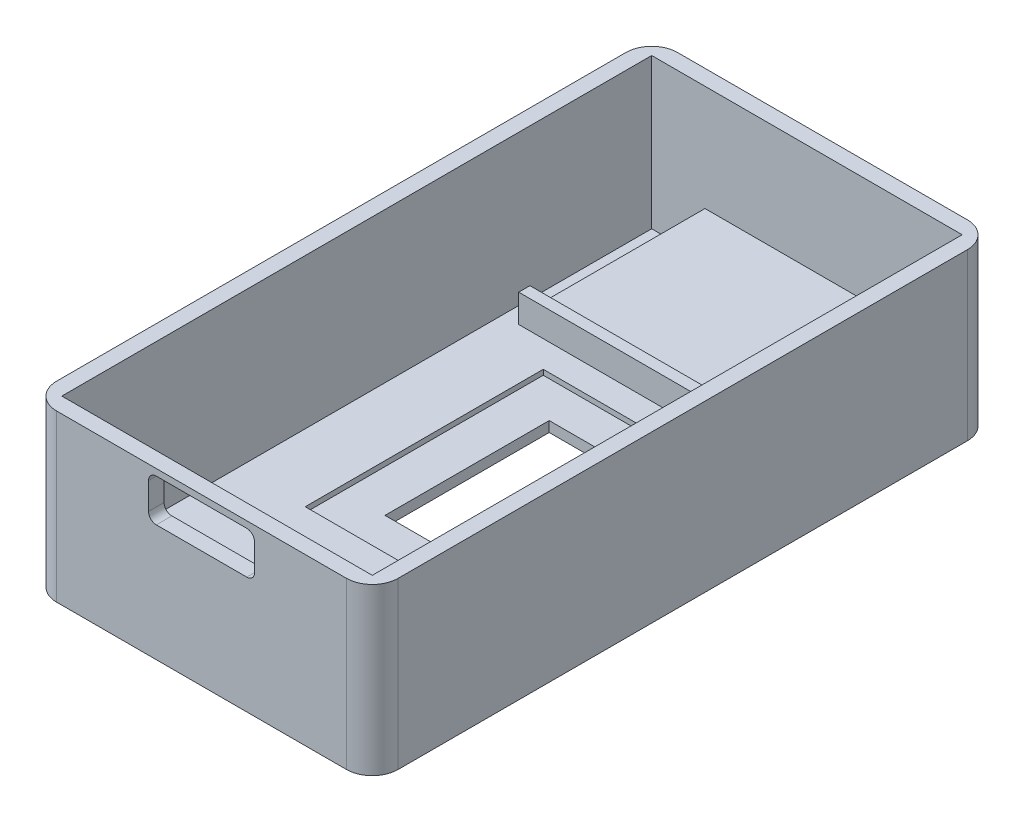
from build123d import *

# Parameters (mm, degrees)
SKETCH1_W               = 33
SKETCH1_H               = 60
BOSS_EXTRUDE1_DEPTH     = 16
SHELL1_T                = -1.5
CUT_EXTRUDE2_DEPTH      = 10
SKETCH5_R               = 1.25
CUT_EXTRUDE3_DEPTH      = 1
CUT_EXTRUDE3_DEPTH_BACK = 3
SKETCH6_W               = 19.561169912
SKETCH6_H               = 0.704256658
BOSS_EXTRUDE2_DEPTH     = 18
SKETCH7_W               = 19.561169912
SKETCH7_H               = 1.086114883
BOSS_EXTRUDE3_DEPTH     = 2
SKETCH9_W               = 16.960059774
SKETCH9_H               = 23
CUT_EXTRUDE4_DEPTH      = 0.5
CUT_EXTRUDE6_REACH      = 18
SKETCH11_W              = 8.91696513
SKETCH11_H              = 15.868910044
FILLET1_R               = 2.5


with BuildPart() as part:
    # Sketch1 → Boss-Extrude1 (new body)
    with BuildSketch(Plane(origin=(0, 0, 0), x_dir=(1, 0, 0), z_dir=(0, 1, 0))):
        with Locations((16.989591658, -18.738797177)):
            Rectangle(SKETCH1_W, SKETCH1_H)
    extrude(amount=BOSS_EXTRUDE1_DEPTH)

    # Shell1
    shell1_openings = [part.faces().sort_by_distance(p)[0] for p in [
        (16.989591658, 16, 18.738797177),
    ]]
    offset(amount=SHELL1_T, openings=shell1_openings, kind=Kind.INTERSECTION)

    # Sketch4 → Cut-Extrude2 (cut)
    with BuildSketch(Plane.XY.offset(48.738797177)):
        with BuildLine():
            Line((12.619091925, 11.287469293), (21.360091391, 11.287469293))
            ThreePointArc((21.360091391, 11.287469293), (21.890421477, 11.507139207), (22.110091391, 12.037469293))
            Line((22.110091391, 12.037469293), (22.110091391, 14.61730298))
            ThreePointArc((22.110091391, 14.61730298), (21.890421477, 15.147633066), (21.360091391, 15.36730298))
            Line((21.360091391, 15.36730298), (12.619091925, 15.36730298))
            ThreePointArc((12.619091925, 15.36730298), (12.088761839, 15.147633066), (11.869091925, 14.61730298))
            Line((11.869091925, 14.61730298), (11.869091925, 12.037469293))
            ThreePointArc((11.869091925, 12.037469293), (12.088761839, 11.507139207), (12.619091925, 11.287469293))
        make_face()
    extrude(amount=-CUT_EXTRUDE2_DEPTH, mode=Mode.SUBTRACT)

    # Sketch5 → Cut-Extrude3 (cut, two sides)
    with BuildSketch(Plane.XZ) as cut_extrude3_sk:
        with Locations((28.889591658, 45.188797177)):
            Circle(SKETCH5_R)
        with Locations((5.089591658, 45.188797177)):
            Circle(SKETCH5_R)
        with Locations((28.889591658, -5.611202823)):
            Circle(SKETCH5_R)
        with Locations((5.089591658, -5.611202823)):
            Circle(SKETCH5_R)
    extrude(amount=CUT_EXTRUDE3_DEPTH, mode=Mode.SUBTRACT)
    extrude(cut_extrude3_sk.sketch, amount=-CUT_EXTRUDE3_DEPTH_BACK, mode=Mode.SUBTRACT)

    # Sketch6 → Boss-Extrude2 (add)
    with BuildSketch(Plane.XY.offset(-9.761202823)):
        with Locations((16.918287272, 5.415344609)):
            Rectangle(SKETCH6_W, SKETCH6_H)
    extrude(amount=BOSS_EXTRUDE2_DEPTH)

    # Sketch7 → Boss-Extrude3 (add)
    with BuildSketch(Plane(origin=(0, 5.767472938, 0), x_dir=(1, 0, 0), z_dir=(0, 1, 0))):
        with Locations((16.918287272, -7.695739736)):
            Rectangle(SKETCH7_W, SKETCH7_H)
    extrude(amount=BOSS_EXTRUDE3_DEPTH)

    # Sketch9 → Cut-Extrude4 (cut)
    with BuildSketch(Plane(origin=(0, 1.5, 0), x_dir=(1, 0, 0), z_dir=(0, 1, 0))):
        with Locations((16.989591658, -18.738797177)):
            Rectangle(SKETCH9_W, SKETCH9_H)
    extrude(amount=-CUT_EXTRUDE4_DEPTH, mode=Mode.SUBTRACT)

    # Sketch11 → Cut-Extrude6 (cut, up to next)
    with BuildSketch(Plane.XZ, mode=Mode.PRIVATE) as cut_extrude6_sk1:
        with Locations((17.046338664, 18.676425411)):
            Rectangle(SKETCH11_W, SKETCH11_H)
    cut_extrude6_tool1 = extrude(cut_extrude6_sk1.sketch, amount=-CUT_EXTRUDE6_REACH, mode=Mode.PRIVATE) & part.part
    add(cut_extrude6_tool1.solids().sort_by_distance((17.046339, 0, 18.676425))[0], mode=Mode.SUBTRACT)

    # Fillet1
    fillet1_edges = [part.edges().sort_by_distance(p)[0] for p in [
        (0.489591658, 8, -11.261202823),
        (33.489591658, 8, -11.261202823),
        (33.489591658, 8, 48.738797177),
        (0.489591658, 8, 48.738797177),
    ]]
    fillet(fillet1_edges, radius=FILLET1_R)


solid = part.part
